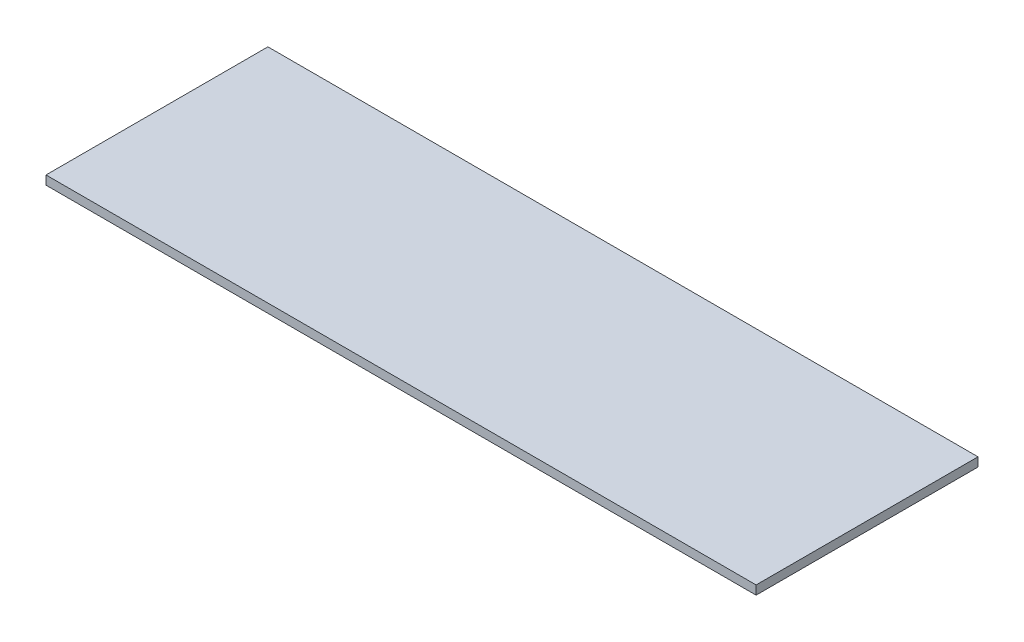
from build123d import *

# Parameters (mm, degrees)
SKETCH1_W           = 160
SKETCH1_H           = 50
BOSS_EXTRUDE1_DEPTH = 2


with BuildPart() as part:
    # Sketch1 → Boss-Extrude1 (new body)
    with BuildSketch(Plane(origin=(0, 0, 0), x_dir=(1, 0, 0), z_dir=(0, 1, 0))):
        with Locations((80, 25)):
            Rectangle(SKETCH1_W, SKETCH1_H)
    extrude(amount=BOSS_EXTRUDE1_DEPTH)


solid = part.part
